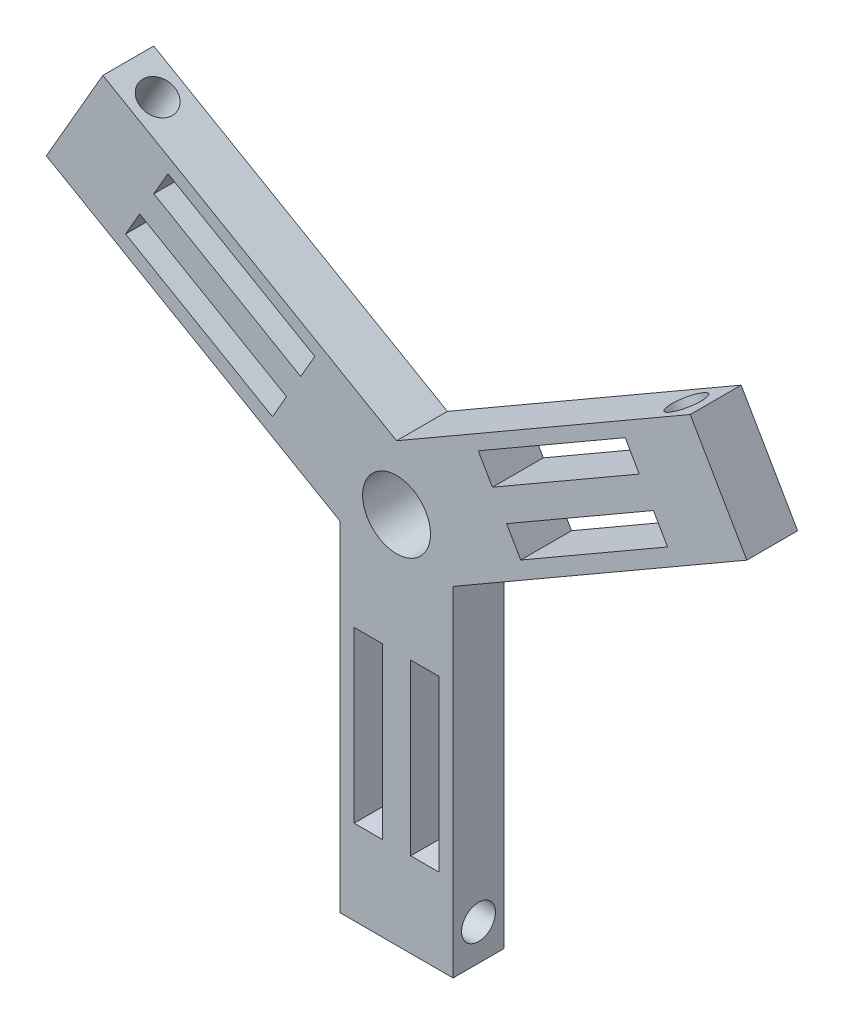
from build123d import *

# Parameters (mm, degrees)
SKETCH2_R           = 60
BOSS_EXTRUDE1_DEPTH = 90
SKETCH4_W           = 50
SKETCH4_H           = 300
CUT_EXTRUDE1_DEPTH  = 90
CIRPATTERN1_COUNT   = 3
SKETCH7_R           = 30
CUT_EXTRUDE2_DEPTH  = 770.615242271
CIRPATTERN2_COUNT   = 3


with BuildPart() as part:
    # Sketch2 → Boss-Extrude1 (new body)
    with BuildSketch(Plane.XY):
        Polygon((-100, -60), (-100, -660), (100, -660), (100, -60), (619.615242271, 240), (519.615242271, 413.205080757), (0, 113.205080757), (-519.615242271, 413.205080757), (-619.615242271, 240), align=None)
        Circle(SKETCH2_R, mode=Mode.SUBTRACT)
    extrude(amount=BOSS_EXTRUDE1_DEPTH)

    # Sketch4 → Cut-Extrude1 (cut)
    with BuildSketch(Plane.XY.offset(90)):
        with Locations((-50, -360.309938914)):
            Rectangle(SKETCH4_W, SKETCH4_H)
        with Locations((50, -360.309938914)):
            Rectangle(SKETCH4_W, SKETCH4_H)
    cut_extrude1 = extrude(amount=-CUT_EXTRUDE1_DEPTH, mode=Mode.SUBTRACT)

    # CirPattern1: Cut-Extrude1 ×3 about axis
    cirpattern1_axis = Axis((0, 0, 0), (0, 0, 1))
    for i in range(1, CIRPATTERN1_COUNT):
        add(cut_extrude1.rotate(cirpattern1_axis, i * 360 / CIRPATTERN1_COUNT), mode=Mode.SUBTRACT)

    # Sketch7 → Cut-Extrude2 (cut, through all)
    with BuildSketch(Plane(origin=(-50.980762114, -88.301270189, 0), x_dir=(0.866025404, -0.5, 0), z_dir=(-0.5, -0.866025404, 0))):
        with Locations((-596.602540378, 45)):
            Circle(SKETCH7_R)
    cut_extrude2 = extrude(amount=-CUT_EXTRUDE2_DEPTH, mode=Mode.SUBTRACT)

    # CirPattern2: Cut-Extrude2 ×3 about axis
    cirpattern2_axis = Axis((0, 0, 0), (0, 0, 1))
    for i in range(1, CIRPATTERN2_COUNT):
        add(cut_extrude2.rotate(cirpattern2_axis, i * 360 / CIRPATTERN2_COUNT), mode=Mode.SUBTRACT)


solid = part.part
